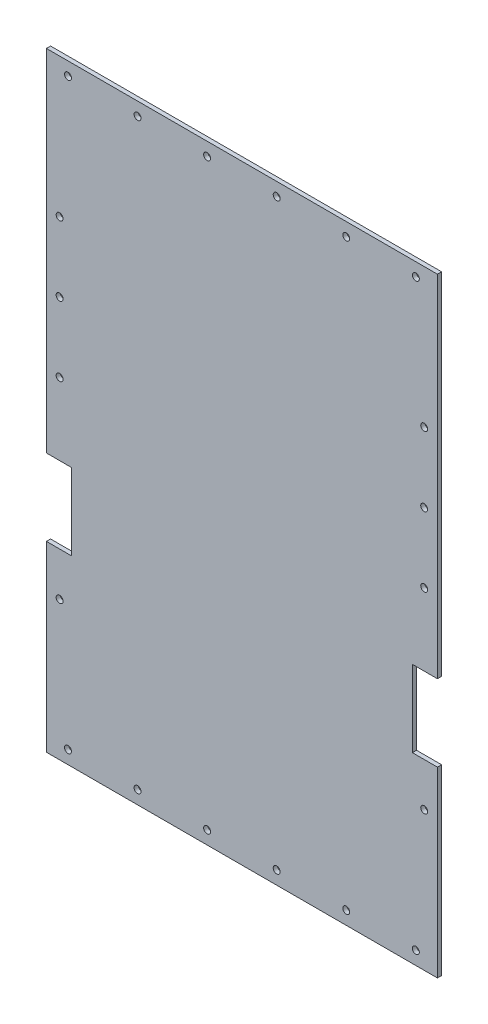
from build123d import *

# Parameters (mm, degrees)
BOSS_EXTRUDE1_DEPTH = 3
SKETCH3_R           = 2.5
CUT_EXTRUDE1_DEPTH  = 4


with BuildPart() as part:
    # Sketch1 → Boss-Extrude1 (new body)
    with BuildSketch(Plane.XY):
        Polygon((0, 186.26), (0, 438.1), (281.05, 438.1), (281.05, 186.26), (263.05, 186.26), (263.05, 131.26), (281.05, 131.26), (281.05, 0), (0, 0), (0, 131.26), (18, 131.26), (18, 186.26), align=None)
    extrude(amount=BOSS_EXTRUDE1_DEPTH)

    # Sketch3 → Cut-Extrude1 (cut, through all)
    with BuildSketch(Plane.XY.offset(3)):
        with Locations((65.525, 428.6)):
            Circle(SKETCH3_R)
        with Locations((115.525, 428.6)):
            Circle(SKETCH3_R)
        with Locations((15.525, 428.6)):
            Circle(SKETCH3_R)
        with Locations((265.525, 428.6)):
            Circle(SKETCH3_R)
        with Locations((165.525, 428.6)):
            Circle(SKETCH3_R)
        with Locations((215.525, 428.6)):
            Circle(SKETCH3_R)
        with Locations((215.525, 9.5)):
            Circle(SKETCH3_R)
        with Locations((165.525, 9.5)):
            Circle(SKETCH3_R)
        with Locations((265.525, 9.5)):
            Circle(SKETCH3_R)
        with Locations((15.525, 9.5)):
            Circle(SKETCH3_R)
        with Locations((115.525, 9.5)):
            Circle(SKETCH3_R)
        with Locations((65.525, 9.5)):
            Circle(SKETCH3_R)
        with Locations((9.5, 338.1)):
            Circle(SKETCH3_R)
        with Locations((9.5, 288.1)):
            Circle(SKETCH3_R)
        with Locations((9.5, 238.1)):
            Circle(SKETCH3_R)
        with Locations((9.5, 100)):
            Circle(SKETCH3_R)
        with Locations((271.55, 100)):
            Circle(SKETCH3_R)
        with Locations((271.55, 238.1)):
            Circle(SKETCH3_R)
        with Locations((271.55, 288.1)):
            Circle(SKETCH3_R)
        with Locations((271.55, 338.1)):
            Circle(SKETCH3_R)
    extrude(amount=-CUT_EXTRUDE1_DEPTH, mode=Mode.SUBTRACT)


solid = part.part
